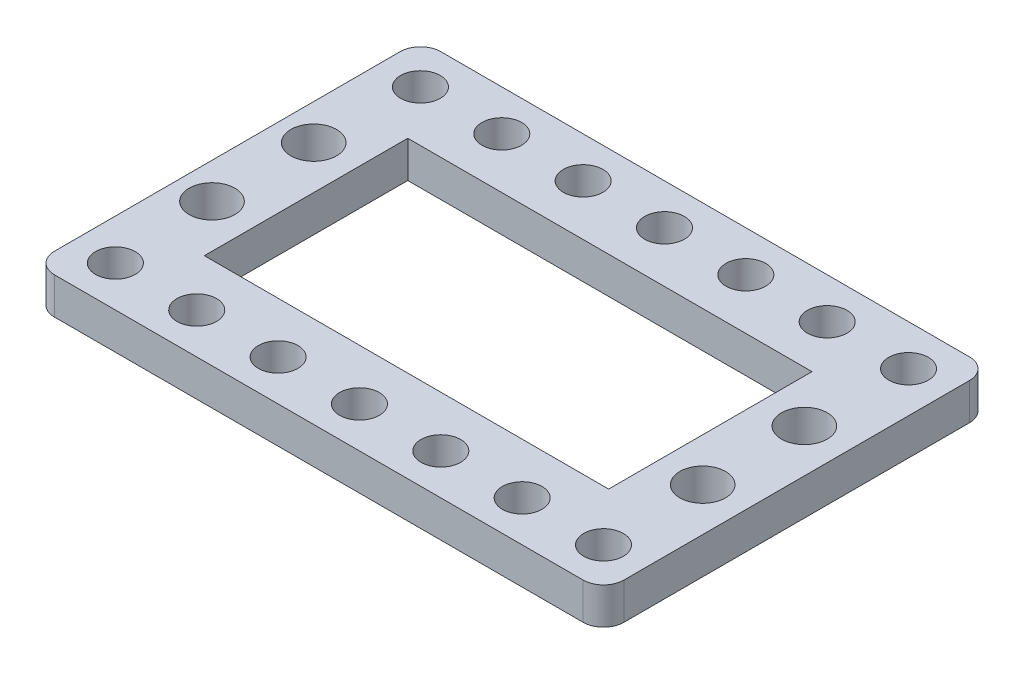
from build123d import *

# Parameters (mm, degrees)
BOSS_EXTRUDE1_DEPTH = 3.6
SKETCH2_R           = 1.95
SKETCH2_W           = 39.75
SKETCH2_H           = 20
CUT_EXTRUDE1_DEPTH  = 3.6
SKETCH4_W           = 22
SKETCH4_H           = 38
CUT_EXTRUDE2_DEPTH  = 10
FILLET1_R           = 2
FILLET2_R           = 2
FILLET3_R           = 2
FILLET4_R           = 2
SKETCH5_R           = 2.25
CUT_EXTRUDE3_DEPTH  = 10


with BuildPart() as part:
    # Sketch1 → Boss-Extrude1 (new body)
    with BuildSketch(Plane(origin=(0, 0, 0), x_dir=(1, 0, 0), z_dir=(0, 1, 0))):
        with BuildLine():
            Line((2, 0), (98, 0))
            ThreePointArc((98, 0), (99.414213562, -0.585786438), (100, -2))
            Line((100, -2), (100, -36))
            ThreePointArc((100, -36), (99.414213562, -37.414213562), (98, -38))
            Line((98, -38), (2, -38))
            ThreePointArc((2, -38), (0.585786438, -37.414213562), (0, -36))
            Line((0, -36), (0, -2))
            ThreePointArc((0, -2), (0.585786438, -0.585786438), (2, 0))
        make_face()
    extrude(amount=BOSS_EXTRUDE1_DEPTH)

    # Sketch2 → Cut-Extrude1 (cut)
    with BuildSketch(Plane(origin=(0, 3.6, 0), x_dir=(1, 0, 0), z_dir=(0, 1, 0))):
        with Locations((90, -4.00475022)):
            Circle(SKETCH2_R)
        with Locations((82, -4.00475022)):
            Circle(SKETCH2_R)
        with Locations((18, -4.00475022)):
            Circle(SKETCH2_R)
        with Locations((26, -4.00475022)):
            Circle(SKETCH2_R)
        with Locations((34, -4.00475022)):
            Circle(SKETCH2_R)
        with Locations((42, -4.00475022)):
            Circle(SKETCH2_R)
        with Locations((50, -4.00475022)):
            Circle(SKETCH2_R)
        with Locations((58, -4.00475022)):
            Circle(SKETCH2_R)
        with Locations((66, -4.00475022)):
            Circle(SKETCH2_R)
        with Locations((74, -4.00475022)):
            Circle(SKETCH2_R)
        with Locations((90, -34)):
            Circle(SKETCH2_R)
        with Locations((82, -34)):
            Circle(SKETCH2_R)
        with Locations((18, -34)):
            Circle(SKETCH2_R)
        with Locations((26, -34)):
            Circle(SKETCH2_R)
        with Locations((34, -34)):
            Circle(SKETCH2_R)
        with Locations((42, -34)):
            Circle(SKETCH2_R)
        with Locations((50, -34)):
            Circle(SKETCH2_R)
        with Locations((58, -34)):
            Circle(SKETCH2_R)
        with Locations((66, -34)):
            Circle(SKETCH2_R)
        with Locations((74, -34)):
            Circle(SKETCH2_R)
        with Locations((49.625, -19)):
            Rectangle(SKETCH2_W, SKETCH2_H)
    extrude(amount=-CUT_EXTRUDE1_DEPTH, mode=Mode.SUBTRACT)

    # Sketch4 → Cut-Extrude2 (cut)
    with BuildSketch(Plane(origin=(0, 3.6, 0), x_dir=(1, 0, 0), z_dir=(0, 1, 0))):
        with Locations((89, -19)):
            Rectangle(SKETCH4_W, SKETCH4_H)
        with Locations((11, -19)):
            Rectangle(SKETCH4_W, SKETCH4_H)
    extrude(amount=-CUT_EXTRUDE2_DEPTH, mode=Mode.SUBTRACT)

    # Fillet1
    fillet1_edges = [part.edges().sort_by_distance(p)[0] for p in [
        (22, 1.8, 0),
    ]]
    fillet(fillet1_edges, radius=FILLET1_R)

    # Fillet2
    fillet2_edges = [part.edges().sort_by_distance(p)[0] for p in [
        (22, 1.8, 38),
    ]]
    fillet(fillet2_edges, radius=FILLET2_R)

    # Fillet3
    fillet3_edges = [part.edges().sort_by_distance(p)[0] for p in [
        (78, 1.8, 38),
    ]]
    fillet(fillet3_edges, radius=FILLET3_R)

    # Fillet4
    fillet4_edges = [part.edges().sort_by_distance(p)[0] for p in [
        (78, 1.8, 0),
    ]]
    fillet(fillet4_edges, radius=FILLET4_R)

    # Sketch5 → Cut-Extrude3 (cut)
    with BuildSketch(Plane(origin=(0, 3.6, 0), x_dir=(1, 0, 0), z_dir=(0, 1, 0))):
        with Locations((73.75, -14)):
            Circle(SKETCH5_R)
        with Locations((73.75, -24)):
            Circle(SKETCH5_R)
        with Locations((25.5, -14)):
            Circle(SKETCH5_R)
        with Locations((25.5, -24)):
            Circle(SKETCH5_R)
    extrude(amount=-CUT_EXTRUDE3_DEPTH, mode=Mode.SUBTRACT)


solid = part.part
